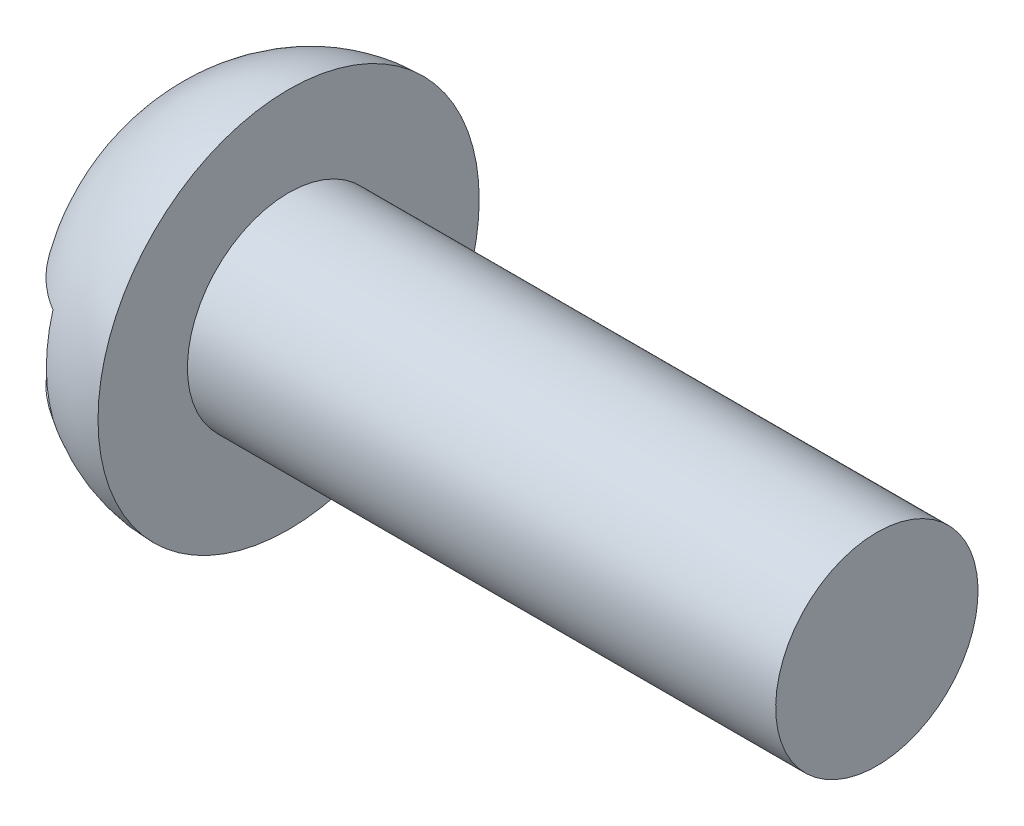
from build123d import *

# Parameters (mm, degrees)
CUT_EXTRUDE1_DEPTH      = 2.54
CUT_EXTRUDE1_DEPTH_BACK = 2.54


with BuildPart() as part:
    # Sketch2 → Revolve1 (revolve)
    with BuildSketch(Plane.XY):
        with BuildLine():
            Line((0, 2.0574), (0, 1.0922))
            Line((0, 1.0922), (6.35, 1.0922))
            Line((6.35, 1.0922), (6.35, 0))
            Line((6.35, 0), (0, 0))
            Line((0, 0), (-1.7526, 0))
            add(Edge.make_bspline(
                [(0, 2.0574), (-1.7526, 2.0574), (-1.7526, 0)],
                knots=[3.141592654, 3.141592654, 3.141592654, 4.71238898, 4.71238898, 4.71238898], degree=2, weights=[1, 0.707106781, 1]))
        make_face()
    revolve(axis=Axis((6.35, 0, 0), (-1, 0, 0)))

    # 3DSketch1 → Cut-Extrude1 (cut, two sides: drawn at the far end of the back side and taken through both)
    with BuildSketch(Plane(origin=(-0.762, 0.508, 0), x_dir=(-0.9284766908852594, -0.37139067635410355, 0), z_dir=(0, 0, 1)).offset(-CUT_EXTRUDE1_DEPTH_BACK)):
        Polygon((0, 0), (0.377332927, 0.943332318), (2.735663722, 0), (2.358330795, -0.943332318), align=None)
    extrude(amount=CUT_EXTRUDE1_DEPTH + CUT_EXTRUDE1_DEPTH_BACK, mode=Mode.SUBTRACT)


solid = part.part
